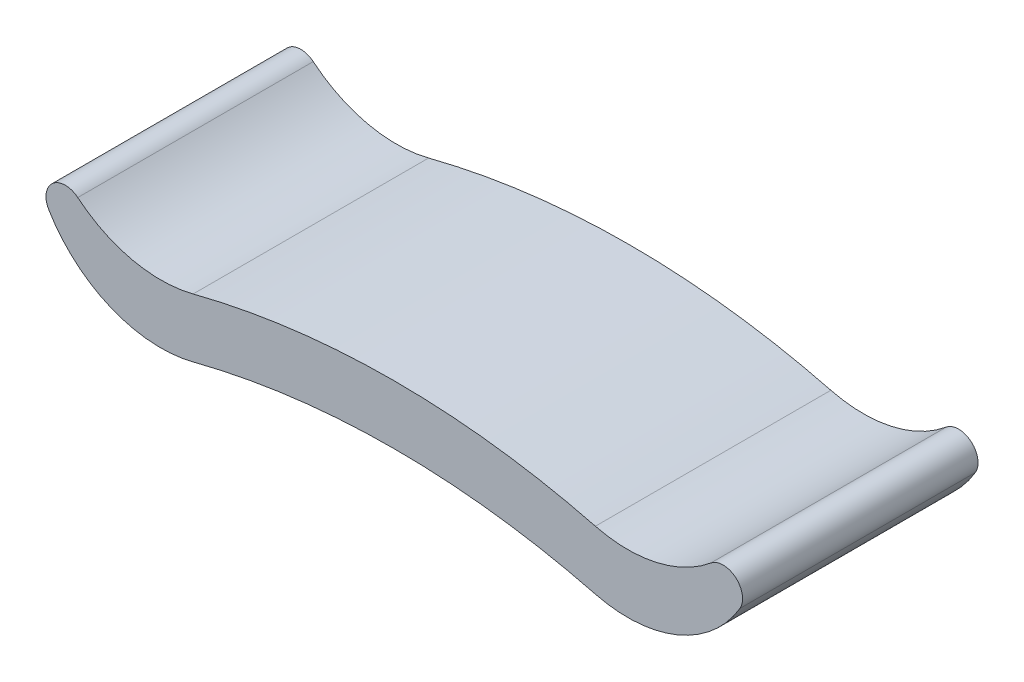
from build123d import *

# Parameters (mm, degrees)
AUFSATZ_LINEAR_AUSTRAGEN1_DEPTH = 120


with BuildPart() as part:
    # Skizze1 → Aufsatz-Linear austragen1 (new body, symmetric)
    with BuildSketch(Plane.XY):
        with BuildLine():
            Line((0, -15), (0, 45))
            ThreePointArc((0, 45), (-103.311330917, 38.513471526), (-205, 19.155766915))
            ThreePointArc((-205, 19.155766915), (-266.956521007, 18.203003185), (-322.60257584, 45.461668516))
            ThreePointArc((-322.60257584, 45.461668516), (-348.070218627, 45.253218096), (-352.237448898, 20.127962424))
            ThreePointArc((-352.237448898, 20.127962424), (-338.919122298, 1.513284408), (-322.60257584, -14.538331484))
            ThreePointArc((-322.60257584, -14.538331484), (-266.956521007, -41.796996815), (-205, -40.844233085))
            ThreePointArc((-205, -40.844233085), (-103.311330917, -21.486528474), (0, -15))
        make_face()
    aufsatz_linear_austragen1 = extrude(amount=AUFSATZ_LINEAR_AUSTRAGEN1_DEPTH, both=True)

    # Spiegeln1: Aufsatz-Linear austragen1 across plane
    add(aufsatz_linear_austragen1.mirror(Plane(origin=(0, 0, 120), x_dir=(0, 0, 1), z_dir=(1, 0, 0))))


solid = part.part
